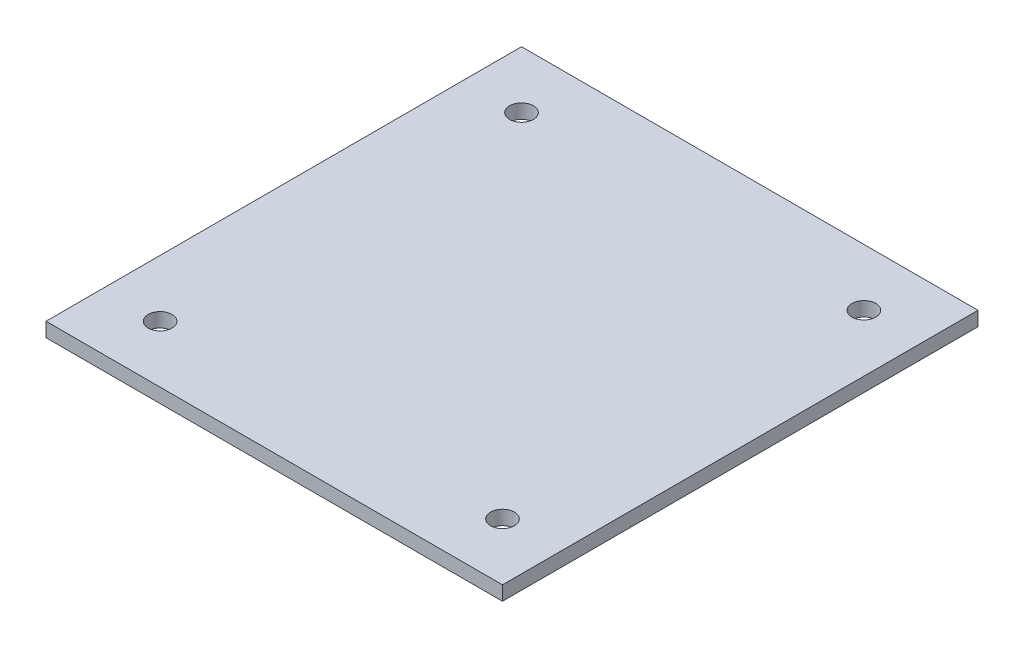
from build123d import *

# Parameters (mm, degrees)
SKETCH1_W           = 152.4
SKETCH1_H           = 158.75
BOSS_EXTRUDE1_DEPTH = 4.7625
SKETCH3_R           = 3.96875
CUT_EXTRUDE2_DEPTH  = 5.7625


with BuildPart() as part:
    # Sketch1 → Boss-Extrude1 (new body)
    with BuildSketch(Plane(origin=(0, 0, 0), x_dir=(1, 0, 0), z_dir=(0, 1, 0))):
        Rectangle(SKETCH1_W, SKETCH1_H)
    extrude(amount=BOSS_EXTRUDE1_DEPTH)

    # Sketch3 → Cut-Extrude2 (cut, through all)
    with BuildSketch(Plane(origin=(0, 4.7625, 0), x_dir=(1, 0, 0), z_dir=(0, 1, 0))):
        with Locations((-57.15, 60.325)):
            Circle(SKETCH3_R)
        with Locations((57.15, 60.325)):
            Circle(SKETCH3_R)
        with Locations((-57.15, -60.325)):
            Circle(SKETCH3_R)
        with Locations((57.15, -60.325)):
            Circle(SKETCH3_R)
    extrude(amount=-CUT_EXTRUDE2_DEPTH, mode=Mode.SUBTRACT)


solid = part.part
